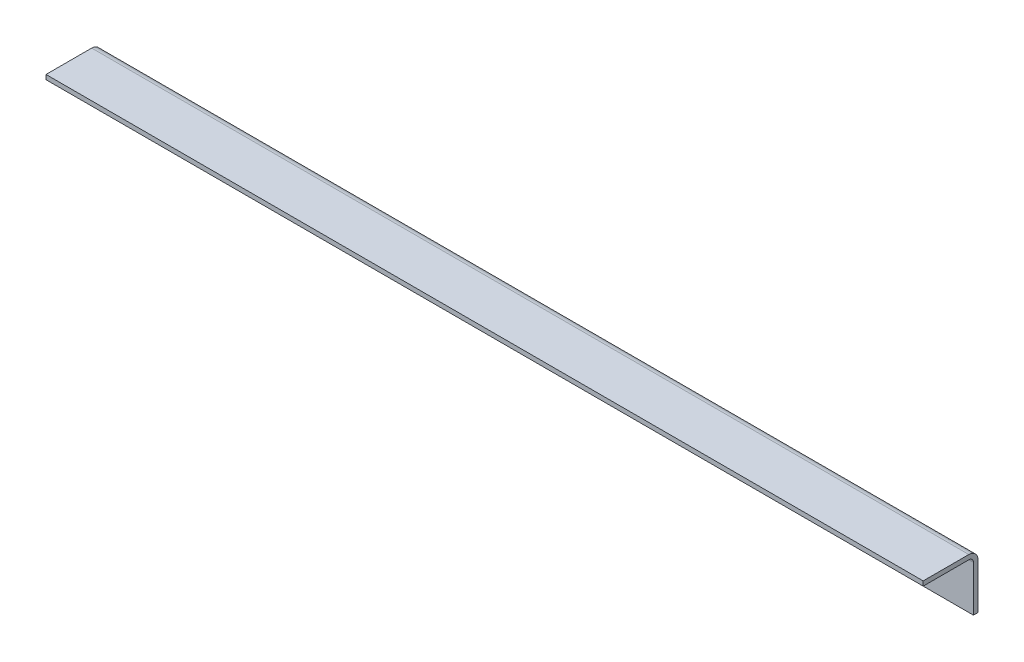
from build123d import *

# Parameters (mm, degrees)
BOSS_EXTRUDE1_DEPTH = 609.6
FILLET1_R           = 3.175
FILLET2_R           = 6.35
SKETCH3_R           = 3.3782
CUT_EXTRUDE1_DEPTH  = 4.175


with BuildPart() as part:
    # Sketch2 → Boss-Extrude1 (new body)
    with BuildSketch(Plane(origin=(0, 0, 0), x_dir=(0, 0, -1), z_dir=(1, 0, 0))):
        Polygon((-38.1, 0), (0, 0), (0, -38.1), (-3.175, -38.1), (-3.175, -3.175), (-38.1, -3.175), align=None)
    extrude(amount=BOSS_EXTRUDE1_DEPTH)

    # Fillet1
    fillet1_edges = [part.edges().sort_by_distance(p)[0] for p in [
        (304.8, -3.175, 3.175),
    ]]
    fillet(fillet1_edges, radius=FILLET1_R)

    # Fillet2
    fillet2_edges = [part.edges().sort_by_distance(p)[0] for p in [
        (304.8, 0, 0),
    ]]
    fillet(fillet2_edges, radius=FILLET2_R)

    # Sketch3 → Cut-Extrude1 (cut, through all)
    with BuildSketch(Plane.XY.offset(3.175)):
        with Locations((304.8, -22.225)):
            Circle(SKETCH3_R)
        with Locations((558.8, -22.225)):
            Circle(SKETCH3_R)
        with Locations((50.8, -22.225)):
            Circle(SKETCH3_R)
    extrude(amount=-CUT_EXTRUDE1_DEPTH, mode=Mode.SUBTRACT)


solid = part.part
